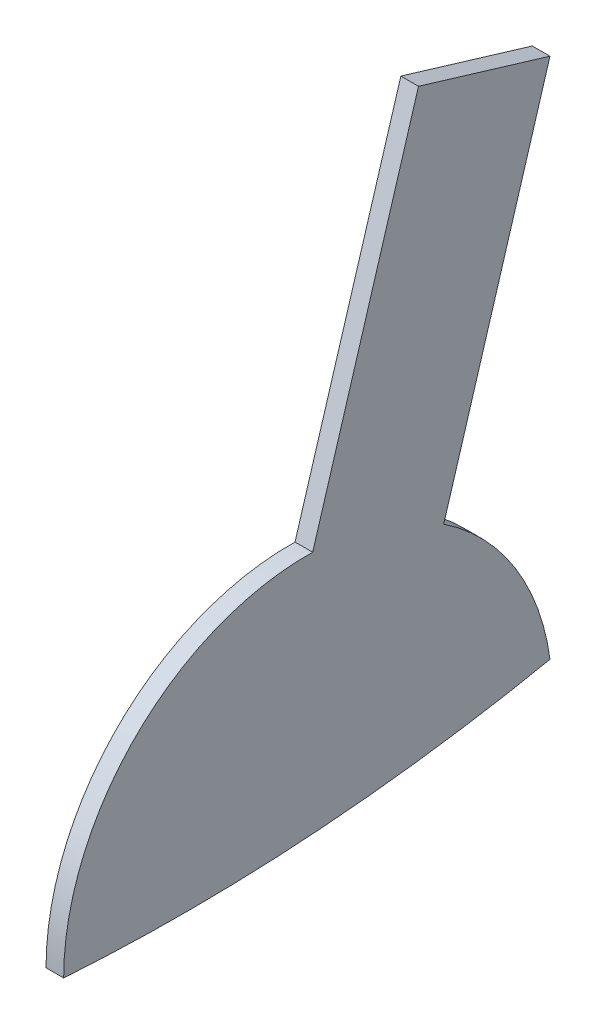
from build123d import *

# Parameters (mm, degrees)
BOSS_EXTRUDE1_DEPTH = 1.5


with BuildPart() as part:
    # Sketch1 (on Right Plane) → Boss-Extrude1 (new body, symmetric)
    with BuildSketch(Plane(origin=(0, 0, 0), x_dir=(0, 0, -1), z_dir=(1, 0, 0))):
        with BuildLine():
            Line((41.140439709, 94.354710036), (23.076518975, 34.512005167))
            ThreePointArc((23.076518975, 34.512005167), (35.21800412, 21.984003604), (41.140439709, 5.573907889))
            add(Edge.make_bspline(
                [(-41.516312801, 0), (0.187936546, -2.786953944), (41.140439709, 5.573907889)],
                knots=[0, 0, 0, 1, 1, 1], degree=2))
            ThreePointArc((-41.516312801, 0), (-29.070108459, 29.640057739), (0.805992023, 41.508488355))
            Line((0.805992023, 41.508488355), (18.79411763, 101.100096824))
            Line((18.79411763, 101.100096824), (41.140439709, 94.354710036))
        make_face()
    extrude(amount=BOSS_EXTRUDE1_DEPTH, both=True)


solid = part.part
